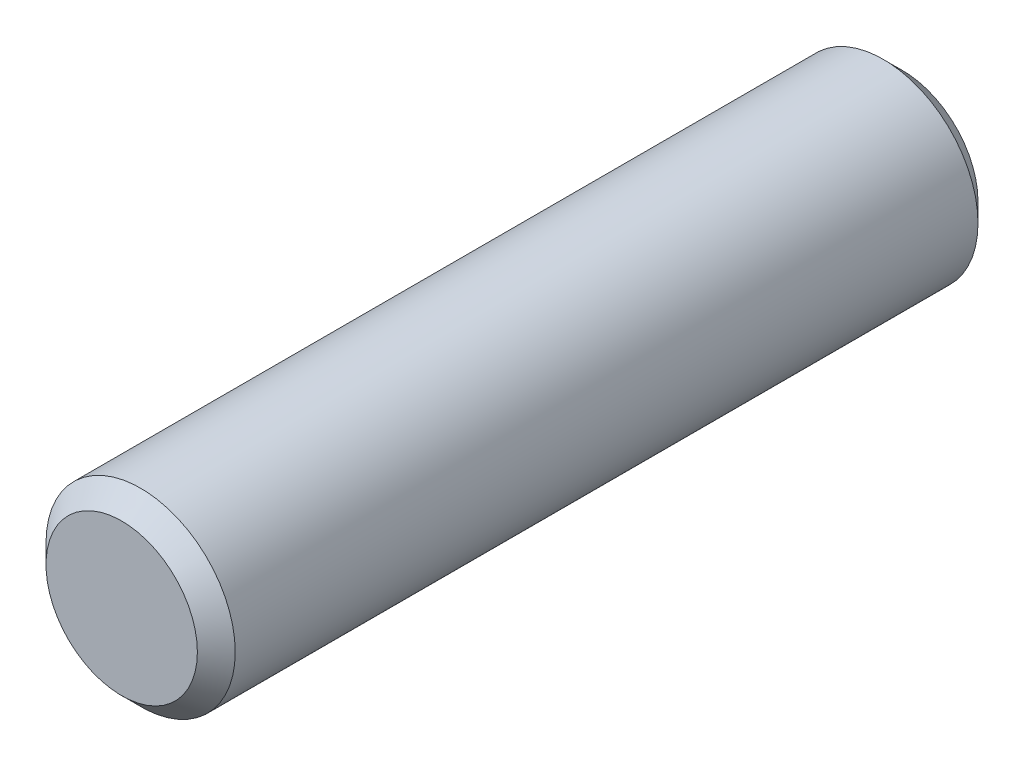
from build123d import *

# Parameters (mm, degrees)
SKETCH1_R      = 4
EXTRUDE1_DEPTH = 16.5
CHAMFER1_SIZE  = 0.8


with BuildPart() as part:
    # Sketch1 → Extrude1 (new body, symmetric)
    with BuildSketch(Plane.XY):
        Circle(SKETCH1_R)
    extrude(amount=EXTRUDE1_DEPTH, both=True)

    # Chamfer1
    chamfer1_edges = [part.edges().sort_by_distance(p)[0] for p in [
        (-4, 0, -16.5),
        (-4, 0, 16.5),
    ]]
    chamfer(chamfer1_edges, length=CHAMFER1_SIZE)


solid = part.part
